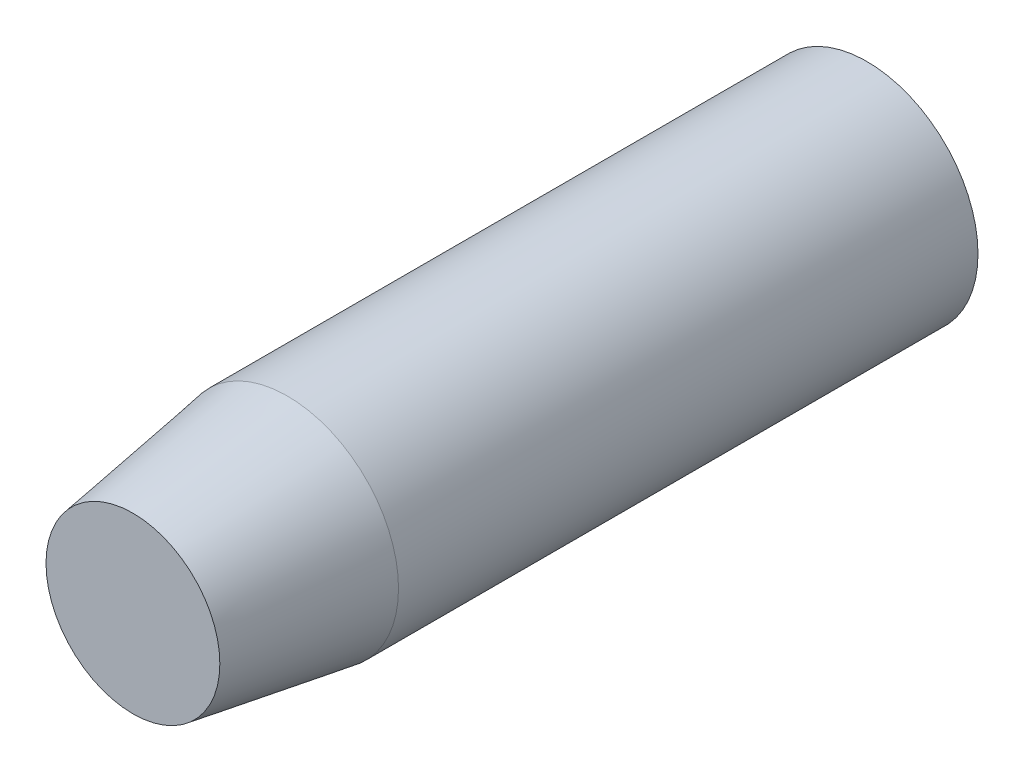
from build123d import *

# Parameters (mm, degrees)
SKETCH1_R           = 18.25625
BOSS_EXTRUDE1_DEPTH = 60.325
CHAMFER1_SIZE       = 25.4
CHAMFER1_SIZE2      = 3.96875


with BuildPart() as part:
    # Sketch1 → Boss-Extrude1 (new body, symmetric)
    with BuildSketch(Plane.XY):
        Circle(SKETCH1_R)
    extrude(amount=BOSS_EXTRUDE1_DEPTH, both=True)

    # Chamfer1
    chamfer1_edges = [part.edges().sort_by_distance(p)[0] for p in [
        (-18.25625, 0, 60.325),
    ]]
    chamfer1_side = [part.faces().sort_by_distance(p)[0] for p in [
        (-18.25625, 0, 0),
    ]]
    chamfer(chamfer1_edges, length=CHAMFER1_SIZE, length2=CHAMFER1_SIZE2, reference=chamfer1_side[0])


solid = part.part
